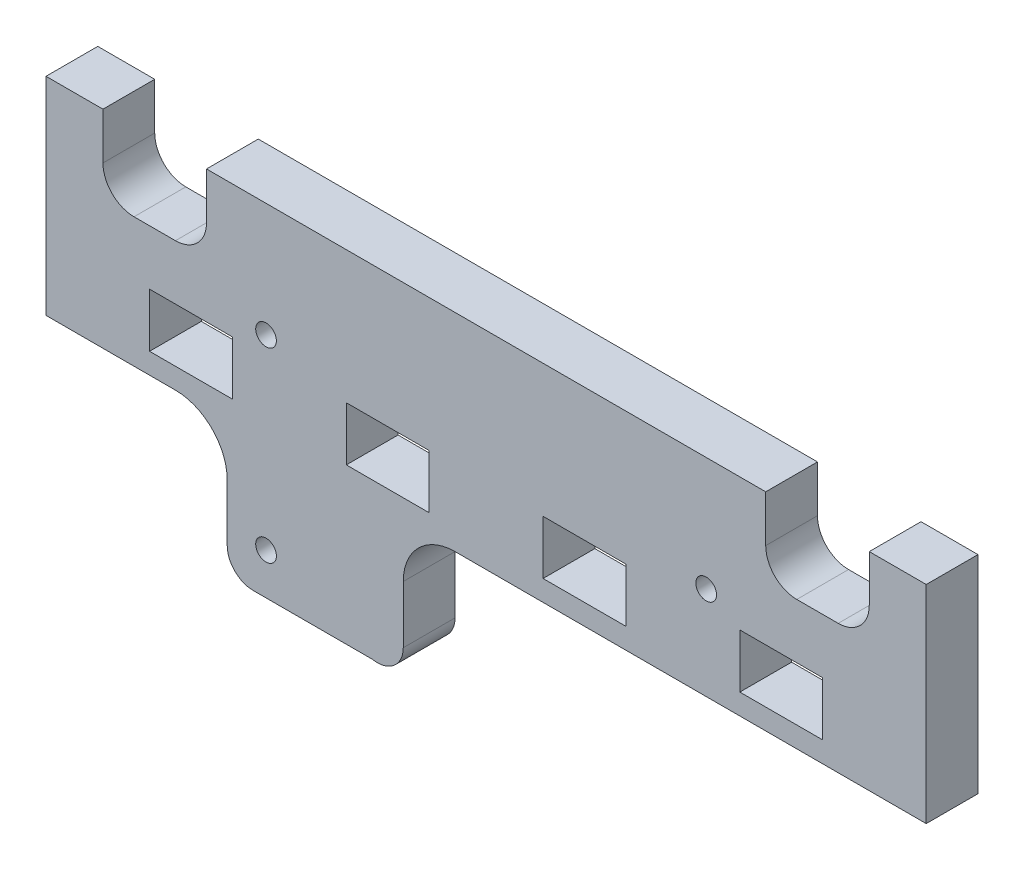
from build123d import *

# Parameters (mm, degrees)
BOSS_EXTRUDE1_DEPTH = 5
CUT_EXTRUDE1_REACH  = 7
SKETCH2_W           = 8
SKETCH2_H           = 5.2
CUT_EXTRUDE2_DEPTH  = 5
CUT_EXTRUDE3_REACH  = 7
SKETCH5_R           = 1


with BuildPart() as part:
    # Sketch1 → Boss-Extrude1 (new body)
    with BuildSketch(Plane.XY):
        with BuildLine():
            Line((24.485627442, 0), (69.985627442, 0))
            Line((69.985627442, 0), (69.985627442, 20))
            Line((69.985627442, 20), (-15.014372558, 20))
            Line((-15.014372558, 20), (-15.014372558, 0))
            Line((-15.014372558, 0), (-2.514372558, 0))
            ThreePointArc((-2.514372558, 0), (1.021161348, -1.464466094), (2.485627442, -5))
            Line((2.485627442, -5), (2.485627442, -10.5))
            ThreePointArc((2.485627442, -10.5), (3.217860489, -12.267766953), (4.985627442, -13))
            Line((4.985627442, -13), (16.528766582, -13))
            ThreePointArc((16.528766582, -13), (18.58372754, -12.464616991), (19.485627442, -10.542098831))
            Line((19.485627442, -10.542098831), (19.485627442, -5))
            ThreePointArc((19.485627442, -5), (20.950093536, -1.464466094), (24.485627442, 0))
        make_face()
    extrude(amount=BOSS_EXTRUDE1_DEPTH)

    # Sketch2 → Cut-Extrude1 (cut, up to next)
    with BuildSketch(Plane.XY.offset(5), mode=Mode.PRIVATE) as cut_extrude1_sk1:
        with Locations((-1.014372558, 4.6)):
            Rectangle(SKETCH2_W, SKETCH2_H)
    cut_extrude1_tool1 = extrude(cut_extrude1_sk1.sketch, amount=-CUT_EXTRUDE1_REACH, mode=Mode.PRIVATE) & part.part
    add(cut_extrude1_tool1.solids().sort_by_distance((-1.014373, 4.6, 5))[0], mode=Mode.SUBTRACT)
    # Sketch2 → Cut-Extrude1 (cut, up to next)
    with BuildSketch(Plane.XY.offset(5), mode=Mode.PRIVATE) as cut_extrude1_sk2:
        with Locations((17.985627442, 4.6)):
            Rectangle(SKETCH2_W, SKETCH2_H)
    cut_extrude1_tool2 = extrude(cut_extrude1_sk2.sketch, amount=-CUT_EXTRUDE1_REACH, mode=Mode.PRIVATE) & part.part
    add(cut_extrude1_tool2.solids().sort_by_distance((17.985627, 4.6, 5))[0], mode=Mode.SUBTRACT)
    # Sketch2 → Cut-Extrude1 (cut, up to next)
    with BuildSketch(Plane.XY.offset(5), mode=Mode.PRIVATE) as cut_extrude1_sk3:
        with Locations((36.985627442, 4.6)):
            Rectangle(SKETCH2_W, SKETCH2_H)
    cut_extrude1_tool3 = extrude(cut_extrude1_sk3.sketch, amount=-CUT_EXTRUDE1_REACH, mode=Mode.PRIVATE) & part.part
    add(cut_extrude1_tool3.solids().sort_by_distance((36.985627, 4.6, 5))[0], mode=Mode.SUBTRACT)
    # Sketch2 → Cut-Extrude1 (cut, up to next)
    with BuildSketch(Plane.XY.offset(5), mode=Mode.PRIVATE) as cut_extrude1_sk4:
        with Locations((55.985627442, 4.6)):
            Rectangle(SKETCH2_W, SKETCH2_H)
    cut_extrude1_tool4 = extrude(cut_extrude1_sk4.sketch, amount=-CUT_EXTRUDE1_REACH, mode=Mode.PRIVATE) & part.part
    add(cut_extrude1_tool4.solids().sort_by_distance((55.985627, 4.6, 5))[0], mode=Mode.SUBTRACT)

    # Sketch3 → Cut-Extrude2 (cut)
    with BuildSketch(Plane.XY.offset(5)):
        with BuildLine():
            Line((-9.514372558, 20), (0.485627442, 20))
            Line((0.485627442, 20), (0.485627442, 15.5))
            ThreePointArc((0.485627442, 15.5), (-0.393052215, 13.378679656), (-2.514372558, 12.5))
            Line((-2.514372558, 12.5), (-6.514372558, 12.5))
            ThreePointArc((-6.514372558, 12.5), (-8.635692902, 13.378679656), (-9.514372558, 15.5))
            Line((-9.514372558, 15.5), (-9.514372558, 20))
        make_face()
    cut_extrude2 = extrude(amount=-CUT_EXTRUDE2_DEPTH, mode=Mode.SUBTRACT)

    # Mirror1: Cut-Extrude2 across plane
    add(cut_extrude2.mirror(Plane(origin=(27.485627442, 0, 0), x_dir=(0, 0, 1), z_dir=(1, 0, 0))), mode=Mode.SUBTRACT)

    # Sketch5 → Cut-Extrude3 (cut, up to next)
    with BuildSketch(Plane.XY.offset(5), mode=Mode.PRIVATE) as cut_extrude3_sk1:
        with Locations((6.235627442, 9)):
            Circle(SKETCH5_R)
    cut_extrude3_tool1 = extrude(cut_extrude3_sk1.sketch, amount=-CUT_EXTRUDE3_REACH, mode=Mode.PRIVATE) & part.part
    add(cut_extrude3_tool1.solids().sort_by_distance((6.235627, 9, 5))[0], mode=Mode.SUBTRACT)
    # Sketch5 → Cut-Extrude3 (cut, up to next)
    with BuildSketch(Plane.XY.offset(5), mode=Mode.PRIVATE) as cut_extrude3_sk2:
        with Locations((48.735627442, 9)):
            Circle(SKETCH5_R)
    cut_extrude3_tool2 = extrude(cut_extrude3_sk2.sketch, amount=-CUT_EXTRUDE3_REACH, mode=Mode.PRIVATE) & part.part
    add(cut_extrude3_tool2.solids().sort_by_distance((48.735627, 9, 5))[0], mode=Mode.SUBTRACT)
    # Sketch5 → Cut-Extrude3 (cut, up to next)
    with BuildSketch(Plane.XY.offset(5), mode=Mode.PRIVATE) as cut_extrude3_sk3:
        with Locations((6.235627442, -9)):
            Circle(SKETCH5_R)
    cut_extrude3_tool3 = extrude(cut_extrude3_sk3.sketch, amount=-CUT_EXTRUDE3_REACH, mode=Mode.PRIVATE) & part.part
    add(cut_extrude3_tool3.solids().sort_by_distance((6.235627, -9, 5))[0], mode=Mode.SUBTRACT)


solid = part.part
